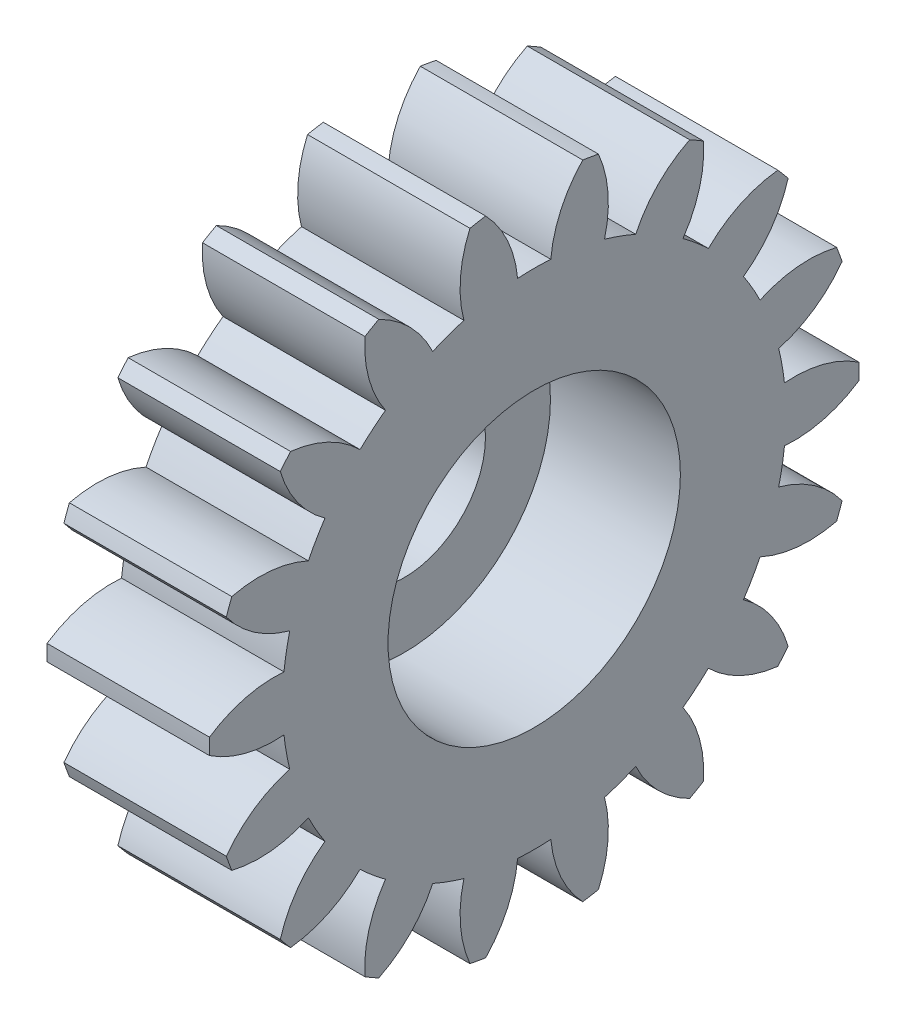
from build123d import *

# Parameters (mm, degrees)
BASPROSKE_W        = 5
BASPROSKE_H        = 10
TOOTHCUT_DEPTH     = 16
TEETHCUTS_COUNT    = 18
TEETHCUTS_ANGLE    = 340
BORSKE_R           = 2.5
BORE_DEPTH         = 50.0000508
SKETCH1_R          = 4.5
CUT_EXTRUDE1_DEPTH = 4


with BuildPart() as part:
    # BasProSke → Base-Revolve (revolve)
    with BuildSketch(Plane(origin=(0, 0, 0), x_dir=(1, 0, 0), z_dir=(0, 1, 0)), mode=Mode.PRIVATE) as base_revolve_sk:
        with Locations((2.5, 5)):
            Rectangle(BASPROSKE_W, BASPROSKE_H)
    revolve(base_revolve_sk.sketch.rotate(Axis((-10, 0, 0), (1, 0, 0)), 180), axis=Axis((-10, 0, 0), (1, 0, 0)))

    # TooCutSke → ToothCut (cut, through all)
    with BuildSketch(Plane(origin=(0, 0, 0), x_dir=(0, 0, -1), z_dir=(1, 0, 0))):
        with BuildLine():
            ThreePointArc((0.510641536, 7.732156635), (0, 7.749), (-0.510641536, 7.732156635))
            ThreePointArc((-0.510641536, 7.732156635), (-0.82619259, 8.907320741), (-1.515208602, 9.910236529))
            ThreePointArc((-1.515208602, 9.910236529), (0, 10.0254), (1.515208602, 9.910236529))
            ThreePointArc((1.515208602, 9.910236529), (0.82619259, 8.907320741), (0.510641536, 7.732156635))
        make_face()
    toothcut = extrude(amount=TOOTHCUT_DEPTH, mode=Mode.SUBTRACT)

    # TeethCuts: ToothCut ×18 about axis
    teethcuts_axis = Axis((-10, 0, 0), (1, 0, 0))
    for i in range(1, TEETHCUTS_COUNT):
        add(toothcut.rotate(teethcuts_axis, i * TEETHCUTS_ANGLE / (TEETHCUTS_COUNT - 1)), mode=Mode.SUBTRACT)

    # BorSke → Bore (cut, symmetric)
    with BuildSketch(Plane(origin=(0, 0, 0), x_dir=(0, 0, -1), z_dir=(1, 0, 0))):
        with Locations(Location((0, 0, 0), (0, 0, 180))):
            Circle(BORSKE_R)
    extrude(amount=BORE_DEPTH, both=True, mode=Mode.SUBTRACT)

    # Sketch1 → Cut-Extrude1 (cut)
    with BuildSketch(Plane(origin=(5, 0, 0), x_dir=(0, 0, -1), z_dir=(1, 0, 0))):
        Circle(SKETCH1_R)
    extrude(amount=-CUT_EXTRUDE1_DEPTH, mode=Mode.SUBTRACT)


solid = part.part
